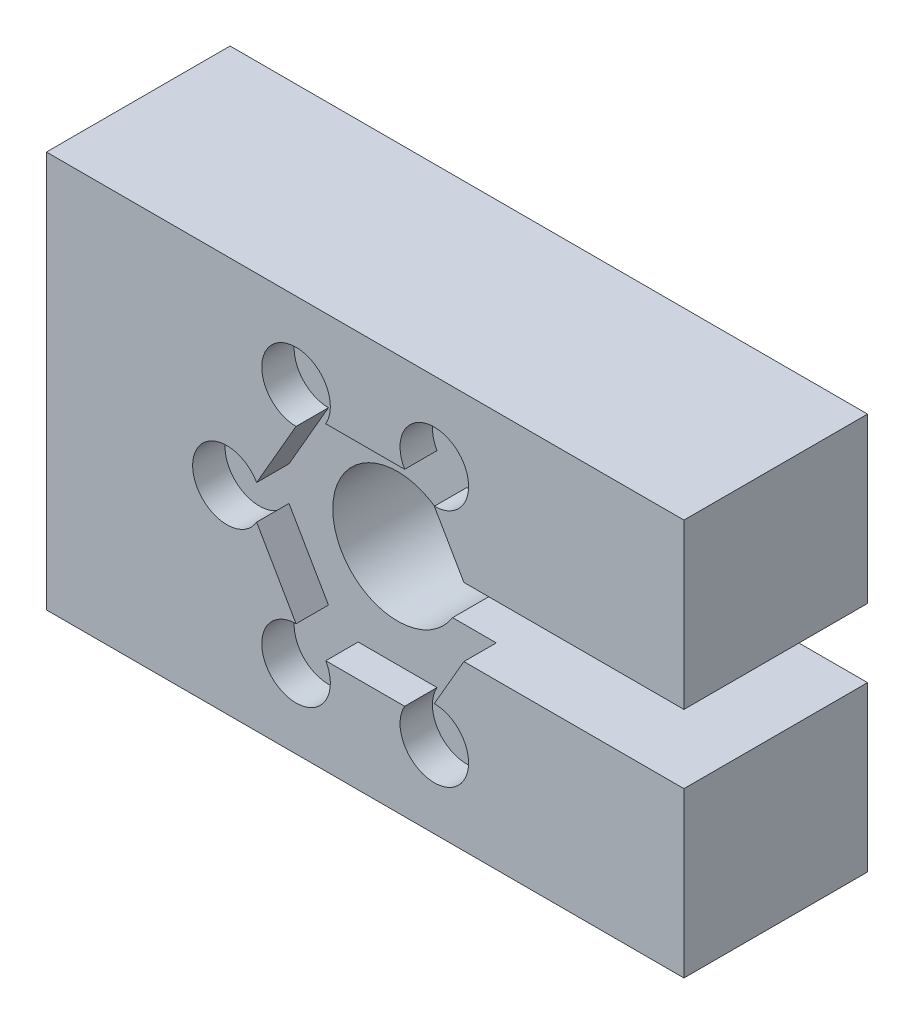
from build123d import *

# Parameters (mm, degrees)
BOSS_EXTRUDE1_DEPTH = 1.5
BOSS_EXTRUDE2_DEPTH = 7
SKETCH5_R           = 1.5875
CUT_EXTRUDE1_DEPTH  = 1.5


with BuildPart() as part:
    # Sketch1 → Boss-Extrude1 (new body)
    with BuildSketch(Plane.XY):
        Polygon((-2.742413779, 4.75), (-5.484827557, 0), (-2.742413779, -4.75), (2.742413779, -4.75), (4.568284005, -1.5875), (14.755382296, -1.5875), (14.755382296, -9.179038244), (-14.755382296, -9.179038244), (-14.755382296, 9.179038244), (14.755382296, 9.179038244), (14.755382296, 1.5875), (4.568284005, 1.5875), (2.742413779, 4.75), align=None)
    extrude(amount=BOSS_EXTRUDE1_DEPTH)

    # Sketch4 → Boss-Extrude2 (add)
    with BuildSketch(Plane(origin=(0, 0, 0), x_dir=(-1, 0, 0), z_dir=(0, 0, -1))):
        with BuildLine():
            Line((-4.568284005, 1.5875), (-2.545553722, 1.5875))
            ThreePointArc((-2.545553722, 1.5875), (3, 0), (-2.545553722, -1.5875))
            Line((-2.545553722, -1.5875), (-4.568284005, -1.5875))
            Line((-4.568284005, -1.5875), (-14.755382296, -1.5875))
            Line((-14.755382296, -1.5875), (-14.755382296, -9.179038244))
            Line((-14.755382296, -9.179038244), (14.755382296, -9.179038244))
            Line((14.755382296, -9.179038244), (14.755382296, 9.179038244))
            Line((14.755382296, 9.179038244), (-14.755382296, 9.179038244))
            Line((-14.755382296, 9.179038244), (-14.755382296, 1.5875))
            Line((-14.755382296, 1.5875), (-4.568284005, 1.5875))
        make_face()
    extrude(amount=BOSS_EXTRUDE2_DEPTH)

    # Sketch5 → Cut-Extrude1 (cut)
    with BuildSketch(Plane.XY.offset(1.5)):
        with Locations((3.200685555, 5.54375)):
            Circle(SKETCH5_R)
        with Locations((6.40137111, 0)):
            Circle(SKETCH5_R)
        with Locations((3.200685555, -5.54375)):
            Circle(SKETCH5_R)
        with Locations((-3.200685555, -5.54375)):
            Circle(SKETCH5_R)
        with Locations((-6.40137111, 0)):
            Circle(SKETCH5_R)
        with Locations((-3.200685555, 5.54375)):
            Circle(SKETCH5_R)
    extrude(amount=-CUT_EXTRUDE1_DEPTH, mode=Mode.SUBTRACT)


solid = part.part
